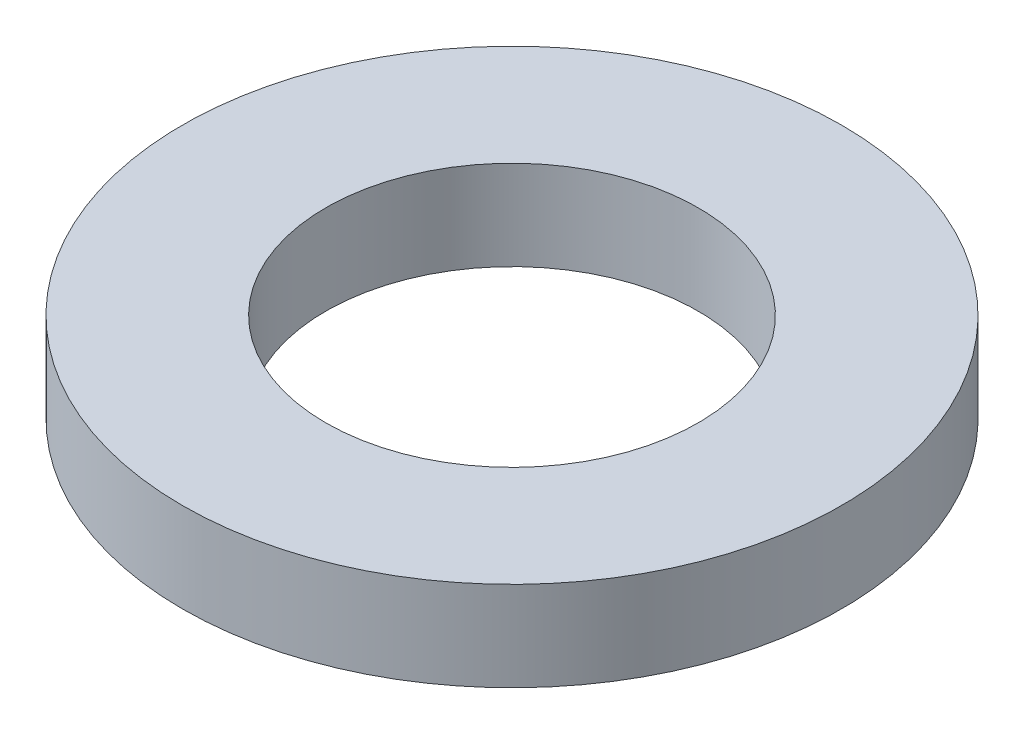
from build123d import *

# Parameters (mm, degrees)
SKETCH1_R           = 5.842
SKETCH1_R_2         = 3.302
BOSS_EXTRUDE1_DEPTH = 1.5875


with BuildPart() as part:
    # Sketch1 → Boss-Extrude1 (new body)
    with BuildSketch(Plane(origin=(0, 0, 0), x_dir=(1, 0, 0), z_dir=(0, 1, 0))):
        Circle(SKETCH1_R)
        Circle(SKETCH1_R_2, mode=Mode.SUBTRACT)
    extrude(amount=BOSS_EXTRUDE1_DEPTH)


solid = part.part
